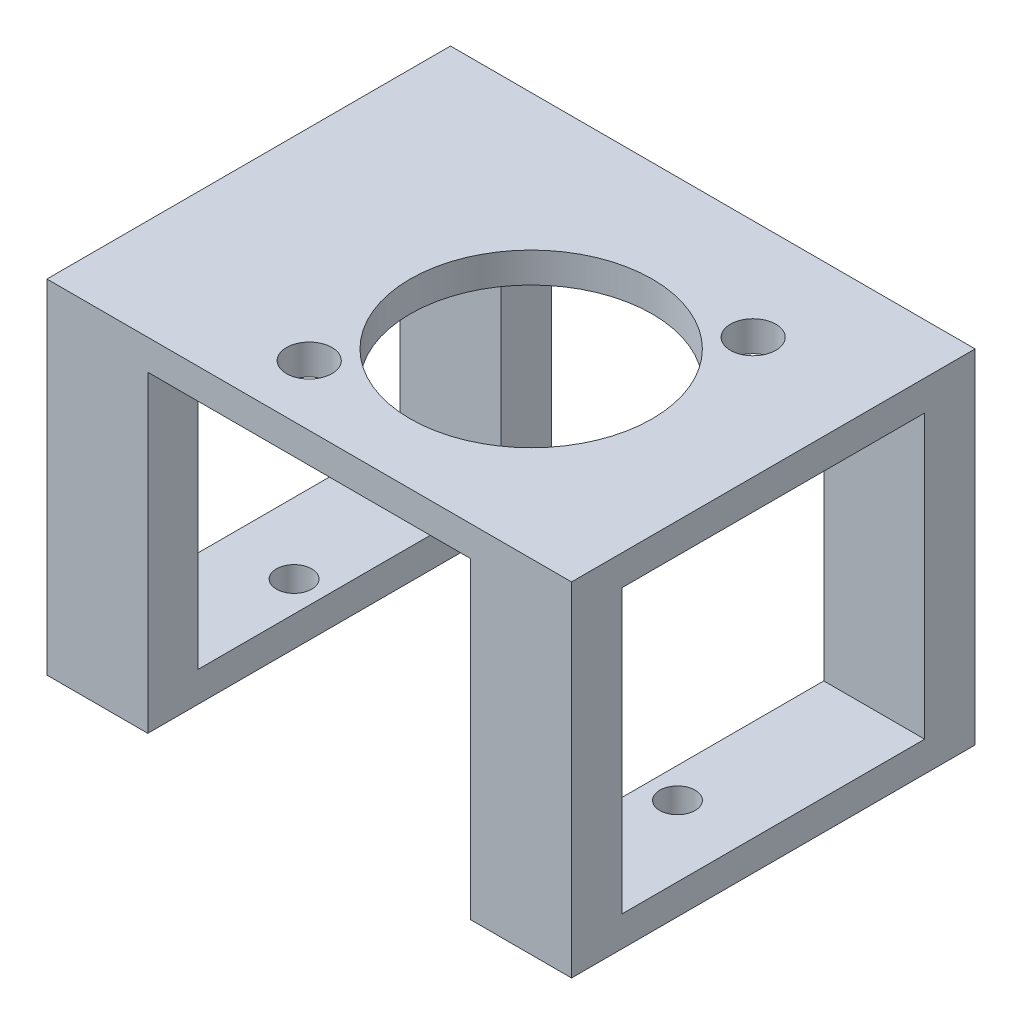
from build123d import *

# Parameters (mm, degrees)
SKETCH1_W             = 10
SKETCH1_H             = 35
BOSS_EXTRUDE1_DEPTH   = 3
BOSS_EXTRUDE1_2_DEPTH = 3
SKETCH1_3_W           = 10
SKETCH1_3_H           = 5
BOSS_EXTRUDE2_DEPTH   = 31
SKETCH7_W             = 52
SKETCH7_H             = 40
BOSS_EXTRUDE3_DEPTH   = 3
SKETCH8_R             = 12
SKETCH8_R_2           = 2.25
CUT_EXTRUDE4_DEPTH    = 3
SKETCH10_R            = 1.75
CUT_EXTRUDE5_DEPTH    = 3
SKETCH11_W            = 10
SKETCH11_H            = 5
BOSS_EXTRUDE4_DEPTH   = 28


with BuildPart() as part:
    # Sketch1 → Boss-Extrude1 (new body)
    with BuildSketch(Plane(origin=(0, 0, 0), x_dir=(1, 0, 0), z_dir=(0, 1, 0))):
        with Locations((21, 0)):
            Rectangle(SKETCH1_W, SKETCH1_H)
    extrude(amount=BOSS_EXTRUDE1_DEPTH)


with BuildPart() as body_2:
    # Sketch1 → Boss-Extrude1 2 (new body)
    with BuildSketch(Plane(origin=(0, 0, 0), x_dir=(1, 0, 0), z_dir=(0, 1, 0))):
        with Locations((-21, 0)):
            Rectangle(SKETCH1_W, SKETCH1_H)
    extrude(amount=BOSS_EXTRUDE1_2_DEPTH)

    # Sketch1_3 → Boss-Extrude2 (add)
    with BuildSketch(Plane(origin=(0, 0, 0), x_dir=(1, 0, 0), z_dir=(0, 1, 0))):
        with Locations((-21, 20)):
            Rectangle(SKETCH1_3_W, SKETCH1_3_H)
        with Locations((21, 20)):
            Rectangle(SKETCH1_3_W, SKETCH1_3_H)
    extrude(amount=BOSS_EXTRUDE2_DEPTH)

    # Sketch7 → Boss-Extrude3 (add)
    with BuildSketch(Plane(origin=(0, 31, 0), x_dir=(1, 0, 0), z_dir=(0, 1, 0))):
        with Locations((0, 2.5)):
            Rectangle(SKETCH7_W, SKETCH7_H)
    extrude(amount=BOSS_EXTRUDE3_DEPTH)

    # Sketch8 → Cut-Extrude4 (cut)
    with BuildSketch(Plane(origin=(0, 34, 0), x_dir=(1, 0, 0), z_dir=(0, 1, 0))):
        with Locations((4, 0.5)):
            Circle(SKETCH8_R)
        with Locations((-6, -11.5)):
            Circle(SKETCH8_R_2)
        with Locations((14, 12.5)):
            Circle(SKETCH8_R_2)
    extrude(amount=-CUT_EXTRUDE4_DEPTH, mode=Mode.SUBTRACT)


with BuildPart() as cut_extrude5_tool:
    # Sketch10 → Cut-Extrude5 (new body)
    with BuildSketch(Plane(origin=(0, 3, 0), x_dir=(1, 0, 0), z_dir=(0, 1, 0))):
        with Locations((-19, 0)):
            Circle(SKETCH10_R)
        with Locations((19, 0)):
            Circle(SKETCH10_R)
    extrude(amount=-CUT_EXTRUDE5_DEPTH)


with BuildPart() as part_1:
    add(part.part)

    # Cut-Extrude5: cut by cut_extrude5_tool
    add(cut_extrude5_tool.part, mode=Mode.SUBTRACT)



with BuildPart() as body_2_1:
    add(body_2.part)

    # Cut-Extrude5: cut by cut_extrude5_tool
    add(cut_extrude5_tool.part, mode=Mode.SUBTRACT)


with BuildPart() as part_2:
    add(part_1.part)

    add(body_2_1.part)  # Boss-Extrude4 merges body 2
    # Sketch11 → Boss-Extrude4 (add)
    with BuildSketch(Plane(origin=(0, 3, 0), x_dir=(1, 0, 0), z_dir=(0, 1, 0))):
        with Locations((-21, -15)):
            Rectangle(SKETCH11_W, SKETCH11_H)
        with Locations((21, -15)):
            Rectangle(SKETCH11_W, SKETCH11_H)
    extrude(amount=BOSS_EXTRUDE4_DEPTH)


solid = part_2.part
